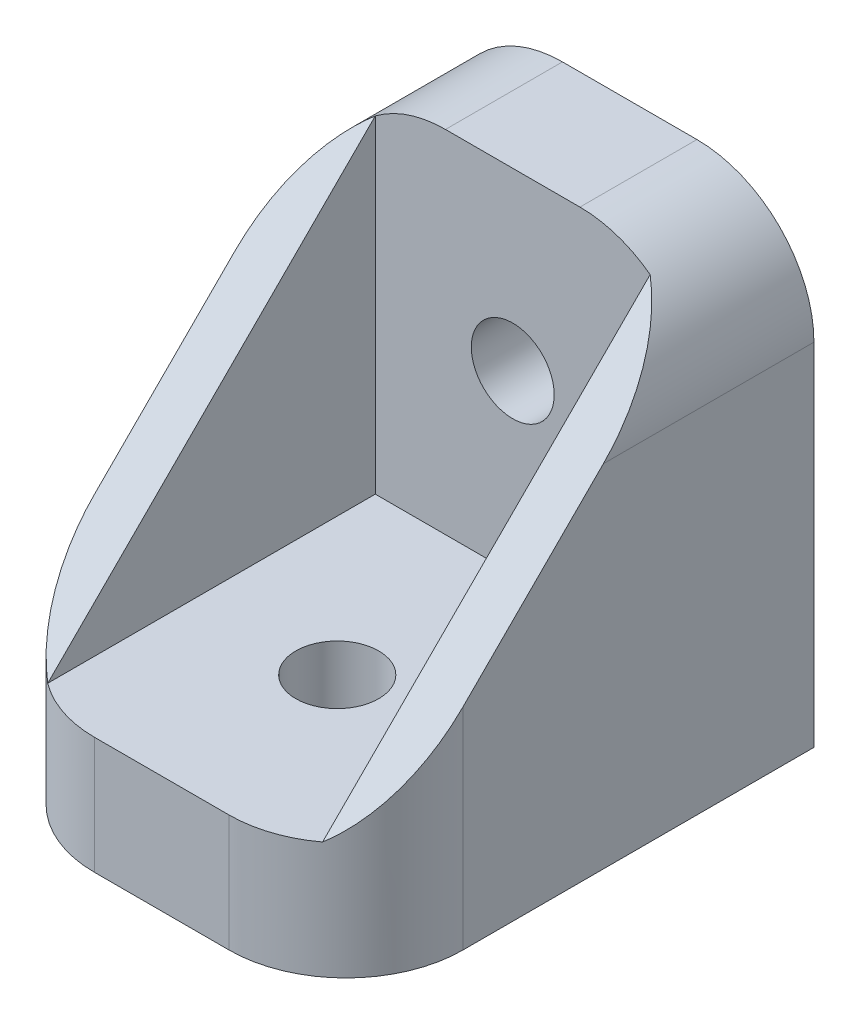
from build123d import *

# Parameters (mm, degrees)
BOSS_EXTRUDE1_DEPTH = 20
CUT_EXTRUDE1_DEPTH  = 20
CUT_EXTRUDE2_DEPTH  = 20
FILLET1_R           = 6.35
BOSS_EXTRUDE2_DEPTH = 19.05
CUT_EXTRUDE3_DEPTH  = 20.05
CUT_EXTRUDE4_DEPTH  = 21


with BuildPart() as part:
    # Sketch1 → Boss-Extrude1 (new body)
    with BuildSketch(Plane(origin=(0, 0, 0), x_dir=(0, 0, -1), z_dir=(1, 0, 0))):
        Polygon((0, 0), (0, 6.35), (19.05, 6.35), (19.05, 25.4), (25.4, 25.4), (25.4, 0), align=None)
    extrude(amount=BOSS_EXTRUDE1_DEPTH)

    # Sketch2 → Cut-Extrude1 (cut)
    with BuildSketch(Plane(origin=(0, 6.35, 0), x_dir=(1, 0, 0), z_dir=(0, 1, 0))):
        with BuildLine():
            ThreePointArc((8.37078656, 11.076825802), (7.750000055, 9.525), (8.37078656, 7.973174198))
            Line((8.37078656, 7.973174198), (10, 9.525))
            Line((10, 9.525), (8.37078656, 11.076825802))
        make_face()
        with BuildLine():
            Line((10, 9.525), (8.37078656, 7.973174198))
            ThreePointArc((8.37078656, 7.973174198), (10, 7.275000055), (11.62921344, 7.973174198))
            Line((11.62921344, 7.973174198), (10, 9.525))
        make_face()
        with BuildLine():
            Line((8.37078656, 11.076825802), (10, 9.525))
            Line((10, 9.525), (11.62921344, 11.076825802))
            ThreePointArc((11.62921344, 11.076825802), (10, 11.774999945), (8.37078656, 11.076825802))
        make_face()
        with BuildLine():
            Line((11.62921344, 11.076825802), (10, 9.525))
            Line((10, 9.525), (11.62921344, 7.973174198))
            ThreePointArc((11.62921344, 7.973174198), (12.089046422, 8.689305797), (12.249999945, 9.525))
            ThreePointArc((12.249999945, 9.525), (12.089046422, 10.360694203), (11.62921344, 11.076825802))
        make_face()
    extrude(amount=-CUT_EXTRUDE1_DEPTH, mode=Mode.SUBTRACT)

    # Sketch3 → Cut-Extrude2 (cut)
    with BuildSketch(Plane.XY.offset(-19.05)):
        with BuildLine():
            ThreePointArc((8.37078652, 17.42682584), (7.75, 15.875), (8.37078652, 14.32317416))
            Line((8.37078652, 14.32317416), (10, 15.875))
            Line((10, 15.875), (8.37078652, 17.42682584))
        make_face()
        with BuildLine():
            Line((10, 15.875), (8.37078652, 14.32317416))
            ThreePointArc((8.37078652, 14.32317416), (10, 13.625), (11.62921348, 14.32317416))
            Line((11.62921348, 14.32317416), (10, 15.875))
        make_face()
        with BuildLine():
            Line((8.37078652, 17.42682584), (10, 15.875))
            Line((10, 15.875), (11.62921348, 17.42682584))
            ThreePointArc((11.62921348, 17.42682584), (10, 18.125), (8.37078652, 17.42682584))
        make_face()
        with BuildLine():
            Line((11.62921348, 17.42682584), (10, 15.875))
            Line((10, 15.875), (11.62921348, 14.32317416))
            ThreePointArc((11.62921348, 14.32317416), (12.089046473, 15.039305777), (12.25, 15.875))
            ThreePointArc((12.25, 15.875), (12.089046473, 16.710694223), (11.62921348, 17.42682584))
        make_face()
    extrude(amount=-CUT_EXTRUDE2_DEPTH, mode=Mode.SUBTRACT)

    # Fillet1
    fillet1_edges = [part.edges().sort_by_distance(p)[0] for p in [
        (20, 25.4, -22.225),
        (20, 3.175, 0),
        (0, 3.175, 0),
        (0, 25.4, -22.225),
    ]]
    fillet(fillet1_edges, radius=FILLET1_R)

    # Sketch4 → Boss-Extrude2 (add)
    with BuildSketch(Plane(origin=(0, 6.35, 0), x_dir=(1, 0, 0), z_dir=(0, 1, 0))):
        with BuildLine():
            Line((2.54, 1.27), (2.54, 19.05))
            Line((2.54, 19.05), (0, 19.05))
            Line((0, 19.05), (0, 6.35))
            ThreePointArc((0, 6.35), (0.670387337, 3.510193669), (2.54, 1.27))
        make_face()
        with BuildLine():
            Line((20, 19.05), (17.46, 19.05))
            Line((17.46, 19.05), (17.46, 1.27))
            ThreePointArc((17.46, 1.27), (19.329612663, 3.510193669), (20, 6.35))
            Line((20, 6.35), (20, 19.05))
        make_face()
    extrude(amount=BOSS_EXTRUDE2_DEPTH)

    # Sketch5 → Cut-Extrude3 (cut, through all)
    with BuildSketch(Plane(origin=(0, 0, -19.05), x_dir=(-1, 0, 0), z_dir=(0, 0, -1))):
        with BuildLine():
            Line((0, 19.05), (0, 25.4))
            Line((0, 25.4), (-2.54, 25.4))
            Line((-2.54, 25.4), (-2.54, 24.13))
            ThreePointArc((-2.54, 24.13), (-0.670387337, 21.889806331), (0, 19.05))
        make_face()
        with BuildLine():
            Line((-17.46, 24.13), (-17.46, 25.4))
            Line((-17.46, 25.4), (-20, 25.4))
            Line((-20, 25.4), (-20, 19.05))
            ThreePointArc((-20, 19.05), (-19.329612663, 21.889806331), (-17.46, 24.13))
        make_face()
    extrude(amount=-CUT_EXTRUDE3_DEPTH, mode=Mode.SUBTRACT)

    # Sketch6 → Cut-Extrude4 (cut, through all)
    with BuildSketch(Plane.ZY):
        Polygon((-13.97, 19.05), (-6.35, 19.05), (-6.35, 11.43), (-1.27, 6.35), (-1.27, 24.13), (-19.05, 24.13), align=None)
        Polygon((-6.35, 11.43), (-6.35, 19.05), (-13.97, 19.05), align=None)
    extrude(amount=-CUT_EXTRUDE4_DEPTH, mode=Mode.SUBTRACT)


solid = part.part
